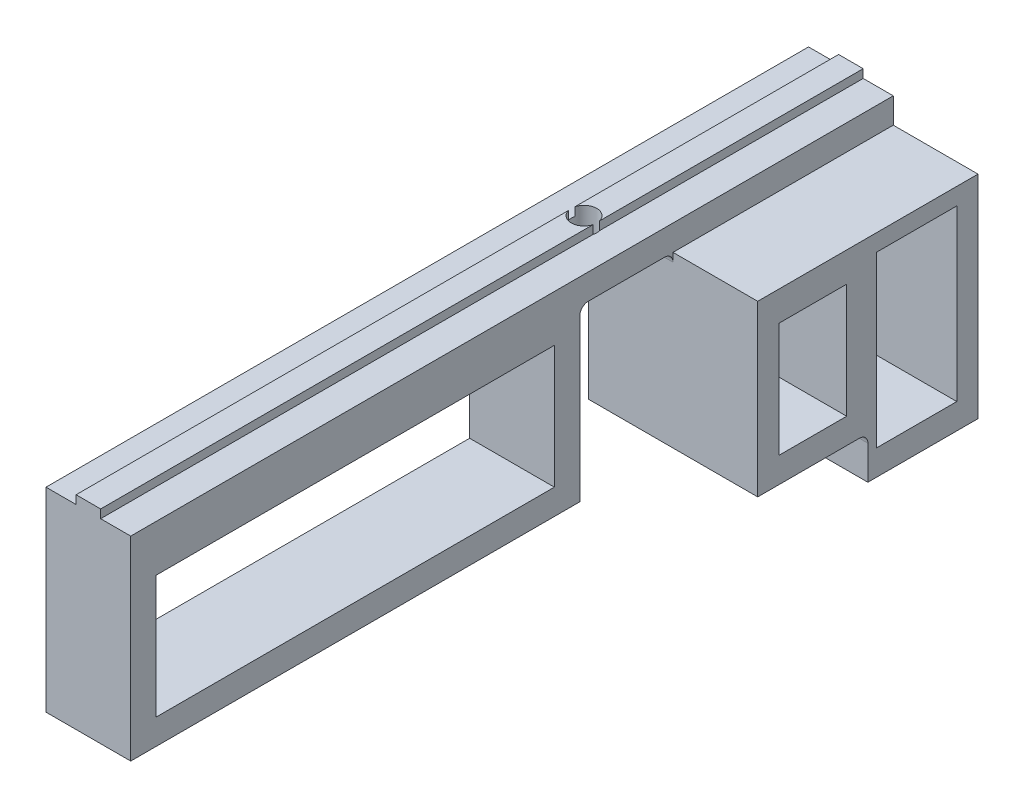
from build123d import *

# Parameters (mm, degrees)
MAKERBEAMFIX_DEPTH            = 45
SKETCH2_R                     = 1.5
MAKERBEAMFIXHOLE_DEPTH        = 5
SKETCH3_W                     = 13
SKETCH3_H                     = 25
SKETCH3_W_2                   = 9.5
SKETCH3_H_2                   = 20
MAKERBEAMTOOLPLATEPLIER_DEPTH = 20
SKETCH4_W                     = 13
SKETCH4_H                     = 20
SKETCH4_W_2                   = 8
SKETCH4_H_2                   = 13.5
MAKERBEAMTOOLCUTPLIER_DEPTH   = 20
SKETCH5_W                     = 53
SKETCH5_H                     = 20
SKETCH5_W_2                   = 47
SKETCH5_H_2                   = 14.5
BIGFACOMPLIER_DEPTH           = 10
FILLET1_R                     = 1


with BuildPart() as part:
    # Sketch1 → MakerBeamFix (new body, symmetric)
    with BuildSketch(Plane.XY):
        Polygon((-5, 0), (5, 0), (5, 3), (1.45, 3), (1.45, 4), (-1.45, 4), (-1.45, 3), (-5, 3), align=None)
    extrude(amount=MAKERBEAMFIX_DEPTH, both=True)

    # Sketch2 → MakerBeamFixHole (cut, through all)
    with BuildSketch(Plane(origin=(0, 0, 0), x_dir=(-1, 0, 0), z_dir=(0, -1, 0))):
        with Locations((0, 13.5)):
            Circle(SKETCH2_R)
    extrude(amount=-MAKERBEAMFIXHOLE_DEPTH, mode=Mode.SUBTRACT)

    # Sketch3 → MakerBeamToolPlatePlier (add)
    with BuildSketch(Plane.ZY.offset(5)):
        with Locations((-38.5, -12.5)):
            Rectangle(SKETCH3_W, SKETCH3_H)
        with Locations((-37.75, -12)):
            Rectangle(SKETCH3_W_2, SKETCH3_H_2, mode=Mode.SUBTRACT)
    extrude(amount=-MAKERBEAMTOOLPLATEPLIER_DEPTH)

    # Sketch4 → MakerBeamToolCutPlier (add)
    with BuildSketch(Plane.ZY.offset(5)):
        with Locations((-25.5, -10)):
            Rectangle(SKETCH4_W, SKETCH4_H)
        with Locations((-25.5, -10.25)):
            Rectangle(SKETCH4_W_2, SKETCH4_H_2, mode=Mode.SUBTRACT)
    extrude(amount=-MAKERBEAMTOOLCUTPLIER_DEPTH)

    # Sketch5 → BigFacomPlier (add)
    with BuildSketch(Plane.ZY.offset(5)):
        with Locations((18.5, -10)):
            Rectangle(SKETCH5_W, SKETCH5_H)
        with Locations((18.5, -9.75)):
            Rectangle(SKETCH5_W_2, SKETCH5_H_2, mode=Mode.SUBTRACT)
    extrude(amount=-BIGFACOMPLIER_DEPTH)

    # Fillet1
    fillet1_edges = [part.edges().sort_by_distance(p)[0] for p in [
        (0, 0, -19),
        (5, -20, -32),
        (0, 0, -8),
    ]]
    fillet(fillet1_edges, radius=FILLET1_R)


solid = part.part
